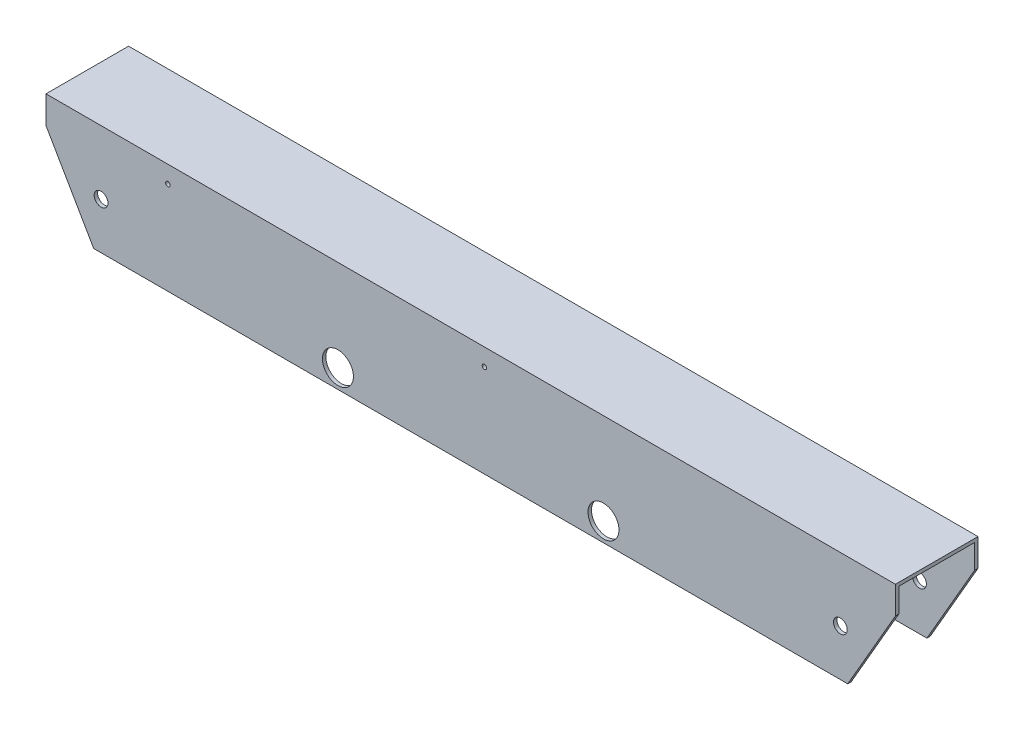
from build123d import *

# Parameters (mm, degrees)
BOSS_EXTRUDE1_DEPTH = 391.865756272
SKETCH2_R           = 6.35
SKETCH2_R_2         = 14.2875
SKETCH2_R_3         = 2.0828
CUT_EXTRUDE1_DEPTH  = 141.732
SKETCH14_R          = 3.302
SKETCH14_W          = 25.4
SKETCH14_H          = 25.4
CUT_EXTRUDE12_DEPTH = 23.114
CUT_EXTRUDE13_DEPTH = 101.6


with BuildPart() as part:
    # Sketch1 → Boss-Extrude1 (new body, symmetric)
    with BuildSketch(Plane(origin=(0, 0, 0), x_dir=(0, 0, -1), z_dir=(1, 0, 0))):
        Polygon((-38.1, 50.8), (38.1, 50.8), (38.1, -50.8), (34.925, -50.8), (34.925, 47.625), (-34.925, 47.625), (-34.925, -50.8), (-38.1, -50.8), align=None)
    extrude(amount=BOSS_EXTRUDE1_DEPTH, both=True)

    # Sketch2 → Cut-Extrude1 (cut)
    with BuildSketch(Plane.XY.offset(38.1)):
        with Locations((-341.065756187, -7.9375)):
            Circle(SKETCH2_R)
        with Locations((122.51182, -33.3375)):
            Circle(SKETCH2_R_2)
        with Locations((341.065756187, -7.9375)):
            Circle(SKETCH2_R)
        with Locations((12.7, 34.925)):
            Circle(SKETCH2_R_3)
        with Locations((-279.4, 34.925)):
            Circle(SKETCH2_R_3)
        with Locations((-122.51182, -33.3375)):
            Circle(SKETCH2_R_2)
    extrude(amount=-CUT_EXTRUDE1_DEPTH, mode=Mode.SUBTRACT)

    # Sketch14 → Cut-Extrude12 (cut)
    with BuildSketch(Plane(origin=(0, 0, -38.1), x_dir=(-1, 0, 0), z_dir=(0, 0, -1))):
        with Locations((-160.61182, -35.123476108)):
            Circle(SKETCH14_R)
        with Locations((-160.61182, 41.076523892)):
            Circle(SKETCH14_R)
        with Locations((-84.41182, 41.076523892)):
            Circle(SKETCH14_R)
        with Locations((-84.41182, -35.123476108)):
            Circle(SKETCH14_R)
        with Locations((-12.7, 34.925)):
            Rectangle(SKETCH14_W, SKETCH14_H)
        with Locations((279.4, 34.925)):
            Rectangle(SKETCH14_W, SKETCH14_H)
    extrude(amount=-CUT_EXTRUDE12_DEPTH, mode=Mode.SUBTRACT)

    # Sketch16 → Cut-Extrude13 (cut)
    with BuildSketch(Plane.XY.offset(38.1)):
        Polygon((-391.865756272, 25.4), (-347.87166576, -50.8), (-391.865756272, -50.8), align=None)
        Polygon((347.87166576, -50.8), (391.865756272, -50.8), (391.865756272, 25.4), align=None)
    extrude(amount=-CUT_EXTRUDE13_DEPTH, mode=Mode.SUBTRACT)


solid = part.part
